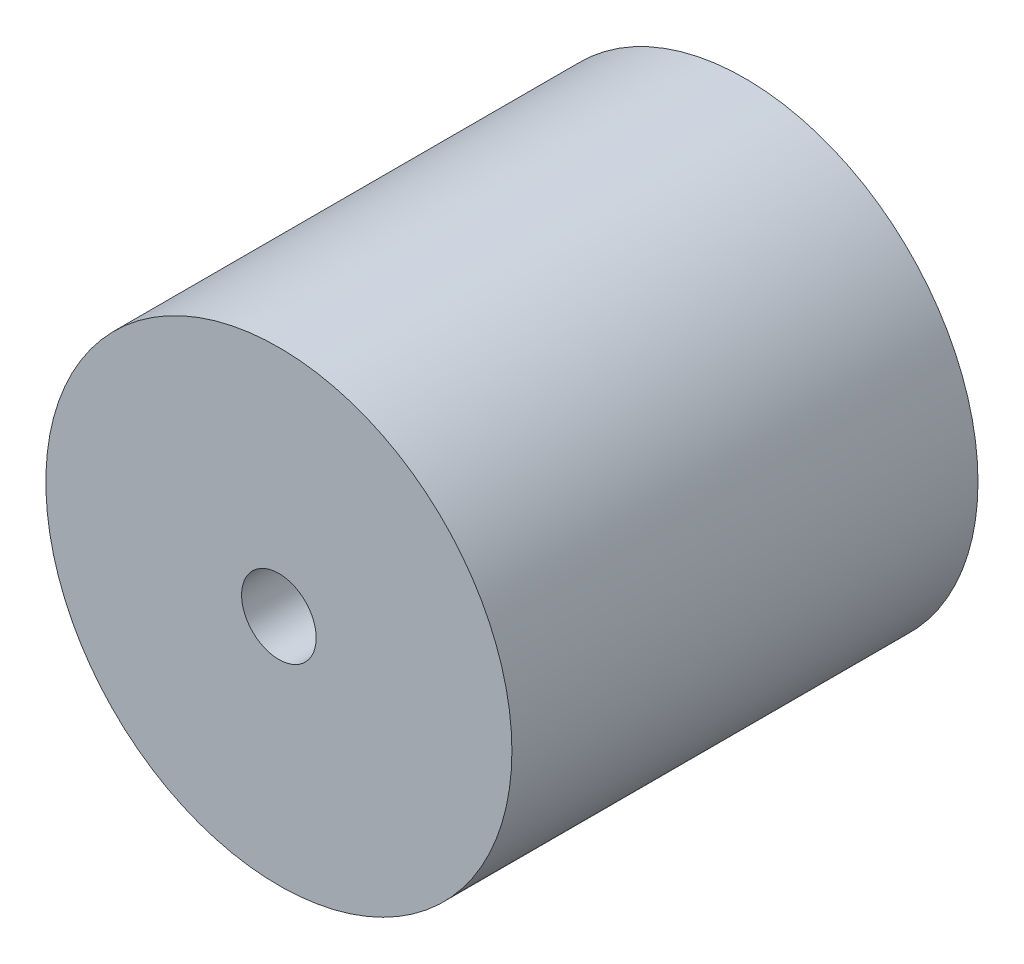
from build123d import *

# Parameters (mm, degrees)
SKETCH1_R           = 12.5
SKETCH1_R_2         = 2
BOSS_EXTRUDE1_DEPTH = 25


with BuildPart() as part:
    # Sketch1 → Boss-Extrude1 (new body)
    with BuildSketch(Plane.XY):
        Circle(SKETCH1_R)
        Circle(SKETCH1_R_2, mode=Mode.SUBTRACT)
    extrude(amount=BOSS_EXTRUDE1_DEPTH)


solid = part.part
